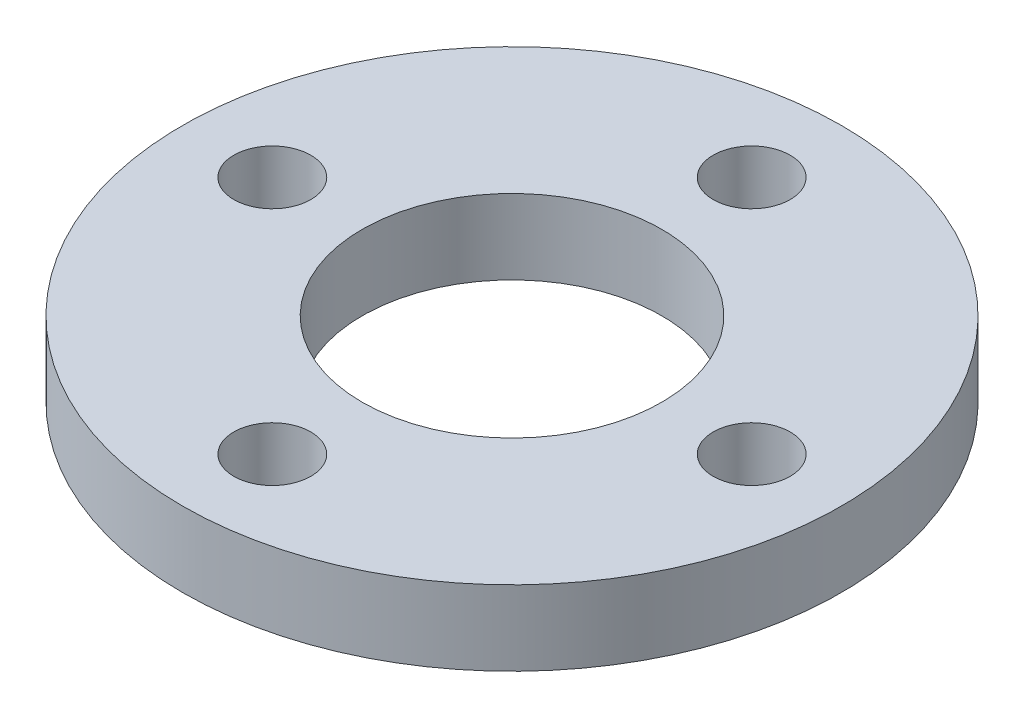
from build123d import *

# Parameters (mm, degrees)
SKETCH1_R           = 13.97
BOSS_EXTRUDE1_DEPTH = 3.175
SKETCH5_R           = 6.35
CUT_EXTRUDE2_DEPTH  = 3.175
CIRPATTERN1_COUNT   = 4


with BuildPart() as part:
    # Sketch1 → Boss-Extrude1 (new body)
    with BuildSketch(Plane(origin=(0, 0, 0), x_dir=(1, 0, 0), z_dir=(0, 1, 0))):
        Circle(SKETCH1_R)
    extrude(amount=BOSS_EXTRUDE1_DEPTH)

    # Sketch5 → Cut-Extrude2 (cut)
    with BuildSketch(Plane(origin=(0, 3.175, 0), x_dir=(1, 0, 0), z_dir=(0, 1, 0))):
        Circle(SKETCH5_R)
    extrude(amount=-CUT_EXTRUDE2_DEPTH, mode=Mode.SUBTRACT)

    # Sketch6 → #4 Clearance Hole1 (revolve, cut)
    with BuildSketch(Plane(origin=(10.16, 3.175, 0), x_dir=(0, 0, 1), z_dir=(1, 0, 0))):
        Polygon((0, 0), (0, 11.140574487), (1.63195, 10.16), (1.63195, 0), align=None)
    f_4_clearance_hole1 = revolve(axis=Axis((10.16, 9.525, 0), (0, -1, 0)), mode=Mode.SUBTRACT)

    # CirPattern1: #4 Clearance Hole1 ×4 about axis
    cirpattern1_axis = Axis((0, 0, 0), (0, 1, 0))
    for i in range(1, CIRPATTERN1_COUNT):
        add(f_4_clearance_hole1.rotate(cirpattern1_axis, i * 360 / CIRPATTERN1_COUNT), mode=Mode.SUBTRACT)


solid = part.part
